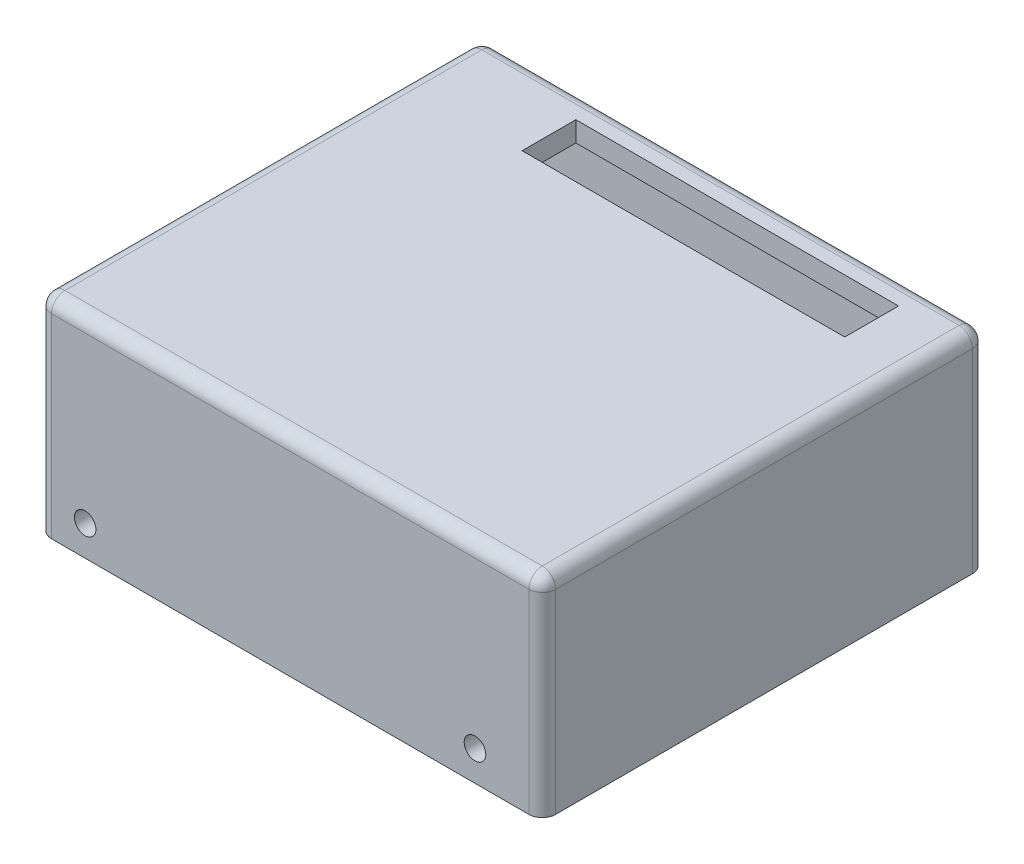
from build123d import *

# Parameters (mm, degrees)
SKETCH1_W               = 78
SKETCH1_H               = 66
SKETCH1_W_2             = 72
SKETCH1_H_2             = 60
BOSS_EXTRUDE1_DEPTH     = 28
SKETCH2_W               = 78
SKETCH2_H               = 66
SKETCH2_W_2             = 48
SKETCH2_H_2             = 8
BOSS_EXTRUDE2_DEPTH     = 3
SKETCH3_W               = 66
SKETCH3_H               = 31
CUT_EXTRUDE1_DEPTH      = 3
SKETCH5_W               = 60
SKETCH5_H               = 4
BOSS_EXTRUDE4_DEPTH     = 3
SKETCH5_4_W             = 45
SKETCH5_4_H             = 8
BOSS_EXTRUDE5_DEPTH     = 3
FILLET1_R               = 1
FILLET2_R               = 2
SKETCH6_R               = 1.605618252
SKETCH6_R_2             = 1.6
CUT_EXTRUDE2_DEPTH      = 17
CUT_EXTRUDE4_DEPTH      = 103
CUT_EXTRUDE4_DEPTH_BACK = 17
SKETCH6_3_R             = 1.605618252
SKETCH6_3_R_2           = 1.6


with BuildPart() as part:
    # Sketch1 → Boss-Extrude1 (new body)
    with BuildSketch(Plane.XZ):
        with Locations((36, 28)):
            Rectangle(SKETCH1_W, SKETCH1_H)
        with Locations((36, 28)):
            Rectangle(SKETCH1_W_2, SKETCH1_H_2, mode=Mode.SUBTRACT)
    extrude(amount=-BOSS_EXTRUDE1_DEPTH)

    # Sketch2 → Boss-Extrude2 (add)
    with BuildSketch(Plane(origin=(0, 28, 0), x_dir=(1, 0, 0), z_dir=(0, 1, 0))):
        with Locations((36, -28)):
            Rectangle(SKETCH2_W, SKETCH2_H)
        with Locations((42, -3)):
            Rectangle(SKETCH2_W_2, SKETCH2_H_2, mode=Mode.SUBTRACT)
    extrude(amount=BOSS_EXTRUDE2_DEPTH)

    # Sketch3 → Cut-Extrude1 (cut)
    with BuildSketch(Plane.ZY.offset(3)):
        with Locations((28, 15.5)):
            Rectangle(SKETCH3_W, SKETCH3_H)
    extrude(amount=-CUT_EXTRUDE1_DEPTH, mode=Mode.SUBTRACT)

    # Sketch5 → Boss-Extrude4 (add)
    with BuildSketch(Plane.ZY):
        with Locations((28, 26)):
            Rectangle(SKETCH5_W, SKETCH5_H)
    extrude(amount=-BOSS_EXTRUDE4_DEPTH)

    # Sketch5_4 → Boss-Extrude5 (add)
    with BuildSketch(Plane.ZY):
        with Locations((20.5, 20)):
            Rectangle(SKETCH5_4_W, SKETCH5_4_H)
    extrude(amount=-BOSS_EXTRUDE5_DEPTH)

    # Fillet1
    fillet1_edges = [part.edges().sort_by_distance(p)[0] for p in [
        (1.5, 16, -2),
        (1.5, 16, 43),
        (1.5, 24, 43),
        (1.5, 24, 58),
    ]]
    fillet(fillet1_edges, radius=FILLET1_R)

    # Fillet2
    fillet2_edges = [part.edges().sort_by_distance(p)[0] for p in [
        (0, 15.5, 61),
        (37.5, 31, 61),
        (75, 15.5, 61),
        (75, 31, 28),
        (0, 31, 28),
        (0, 15.5, -5),
        (37.5, 31, -5),
        (75, 15.5, -5),
    ]]
    fillet(fillet2_edges, radius=FILLET2_R)

    # Sketch6 → Cut-Extrude2 (cut)
    with BuildSketch(Plane(origin=(0, 0, 58), x_dir=(-1, 0, 0), z_dir=(0, 0, -1))):
        with Locations((-64.99455474, 4.498616562)):
            Circle(SKETCH6_R)
        with Locations((-7, 4.5)):
            Circle(SKETCH6_R_2)
    extrude(amount=-CUT_EXTRUDE2_DEPTH, mode=Mode.SUBTRACT)

    # Sketch6_3 → Cut-Extrude4 (cut, two sides: drawn at the far end of the back side and taken through both)
    with BuildSketch(Plane(origin=(0, 0, 58), x_dir=(-1, 0, 0), z_dir=(0, 0, -1)).offset(-CUT_EXTRUDE4_DEPTH_BACK)):
        with Locations((-64.99455474, 4.498616562)):
            Circle(SKETCH6_3_R)
        with Locations((-7, 4.5)):
            Circle(SKETCH6_3_R_2)
    extrude(amount=CUT_EXTRUDE4_DEPTH + CUT_EXTRUDE4_DEPTH_BACK, mode=Mode.SUBTRACT)


solid = part.part
